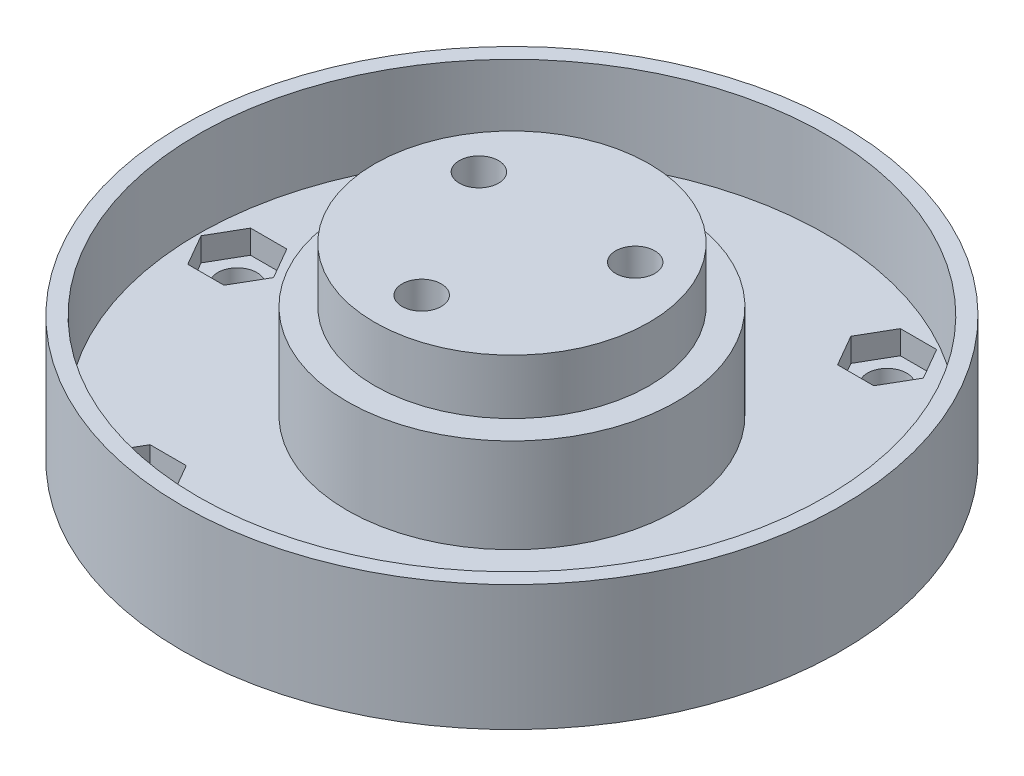
from build123d import *

# Parameters (mm, degrees)
SKETCH1_R           = 17.5
SKETCH1_R_2         = 2.5
BOSS_EXTRUDE1_DEPTH = 24
SKETCH1_3_R         = 21
SKETCH1_3_R_2       = 17.5
BOSS_EXTRUDE2_DEPTH = 17
SKETCH1_6_R         = 40
SKETCH1_6_R_2       = 21
BOSS_EXTRUDE4_DEPTH = 5
SKETCH1_7_R         = 42
SKETCH1_7_R_2       = 40
BOSS_EXTRUDE5_DEPTH = 16
SKETCH2_R           = 2.5
CUT_EXTRUDE1_DEPTH  = 63.361847311
CUT_EXTRUDE2_DEPTH  = 3
CUT_EXTRUDE3_DEPTH  = 20


with BuildPart() as part:
    # Sketch1 → Boss-Extrude1 (new body)
    with BuildSketch(Plane(origin=(0, 0, 0), x_dir=(1, 0, 0), z_dir=(0, 1, 0))):
        Circle(SKETCH1_R)
        with Locations((0, -11.5)):
            Circle(SKETCH1_R_2, mode=Mode.SUBTRACT)
        with Locations((-9.959292144, 5.75)):
            Circle(SKETCH1_R_2, mode=Mode.SUBTRACT)
        with Locations((9.959292144, 5.75)):
            Circle(SKETCH1_R_2, mode=Mode.SUBTRACT)
    extrude(amount=BOSS_EXTRUDE1_DEPTH)

    # Sketch1_3 → Boss-Extrude2 (add)
    with BuildSketch(Plane(origin=(0, 0, 0), x_dir=(1, 0, 0), z_dir=(0, 1, 0))):
        Circle(SKETCH1_3_R)
        Circle(SKETCH1_3_R_2, mode=Mode.SUBTRACT)
    extrude(amount=BOSS_EXTRUDE2_DEPTH)

    # Sketch1_6 → Boss-Extrude4 (add)
    with BuildSketch(Plane(origin=(0, 0, 0), x_dir=(1, 0, 0), z_dir=(0, 1, 0))):
        Circle(SKETCH1_6_R)
        Circle(SKETCH1_6_R_2, mode=Mode.SUBTRACT)
    extrude(amount=BOSS_EXTRUDE4_DEPTH)

    # Sketch1_7 → Boss-Extrude5 (add)
    with BuildSketch(Plane(origin=(0, 0, 0), x_dir=(1, 0, 0), z_dir=(0, 1, 0))):
        Circle(SKETCH1_7_R)
        Circle(SKETCH1_7_R_2, mode=Mode.SUBTRACT)
    extrude(amount=BOSS_EXTRUDE5_DEPTH)

    # Sketch2 → Cut-Extrude1 (cut, through all)
    with BuildSketch(Plane(origin=(0, 5, 0), x_dir=(1, 0, 0), z_dir=(0, 1, 0))):
        with Locations((-35, 0)):
            Circle(SKETCH2_R)
        with Locations((-17.5, 30.310889132)):
            Circle(SKETCH2_R)
        with Locations((17.5, 30.310889132)):
            Circle(SKETCH2_R)
        with Locations((35, 0)):
            Circle(SKETCH2_R)
        with Locations((17.5, -30.310889132)):
            Circle(SKETCH2_R)
        with Locations((-17.5, -30.310889132)):
            Circle(SKETCH2_R)
    extrude(amount=-CUT_EXTRUDE1_DEPTH, mode=Mode.SUBTRACT)

    # Sketch3 → Cut-Extrude2 (cut)
    with BuildSketch(Plane(origin=(0, 5, 0), x_dir=(1, 0, 0), z_dir=(0, 1, 0))):
        Polygon((-12.881197846, 30.310889132), (-15.190598923, 34.310889132), (-19.809401077, 34.310889132), (-22.118802154, 30.310889132), (-19.809401077, 26.310889132), (-15.190598923, 26.310889132), align=None)
        Polygon((19.809401077, 26.310889132), (22.118802154, 30.310889132), (19.809401077, 34.310889132), (15.190598923, 34.310889132), (12.881197846, 30.310889132), (15.190598923, 26.310889132), align=None)
        Polygon((32.690598923, -4), (37.309401077, -4), (39.618802154, 0), (37.309401077, 4), (32.690598923, 4), (30.381197846, 0), align=None)
        Polygon((12.881197846, -30.310889132), (15.190598923, -34.310889132), (19.809401077, -34.310889132), (22.118802154, -30.310889132), (19.809401077, -26.310889132), (15.190598923, -26.310889132), align=None)
        Polygon((-19.809401077, -26.310889132), (-22.118802154, -30.310889132), (-19.809401077, -34.310889132), (-15.190598923, -34.310889132), (-12.881197846, -30.310889132), (-15.190598923, -26.310889132), align=None)
        Polygon((-32.690598923, 4), (-37.309401077, 4), (-39.618802154, 0), (-37.309401077, -4), (-32.690598923, -4), (-30.381197846, 0), align=None)
    extrude(amount=-CUT_EXTRUDE2_DEPTH, mode=Mode.SUBTRACT)

    # Sketch4 → Cut-Extrude3 (cut)
    with BuildSketch(Plane.XZ):
        Polygon((0, 6.881197846), (4, 9.190598923), (4, 13.809401077), (0, 16.118802154), (-4, 13.809401077), (-4, 9.190598923), align=None)
        Polygon((5.959292144, -3.440598923), (5.959292144, -8.059401077), (9.959292144, -10.368802154), (13.959292144, -8.059401077), (13.959292144, -3.440598923), (9.959292144, -1.131197846), align=None)
        Polygon((-5.959292144, -3.440598923), (-9.959292144, -1.131197846), (-13.959292144, -3.440598923), (-13.959292144, -8.059401077), (-9.959292144, -10.368802154), (-5.959292144, -8.059401077), align=None)
    extrude(amount=-CUT_EXTRUDE3_DEPTH, mode=Mode.SUBTRACT)


solid = part.part
